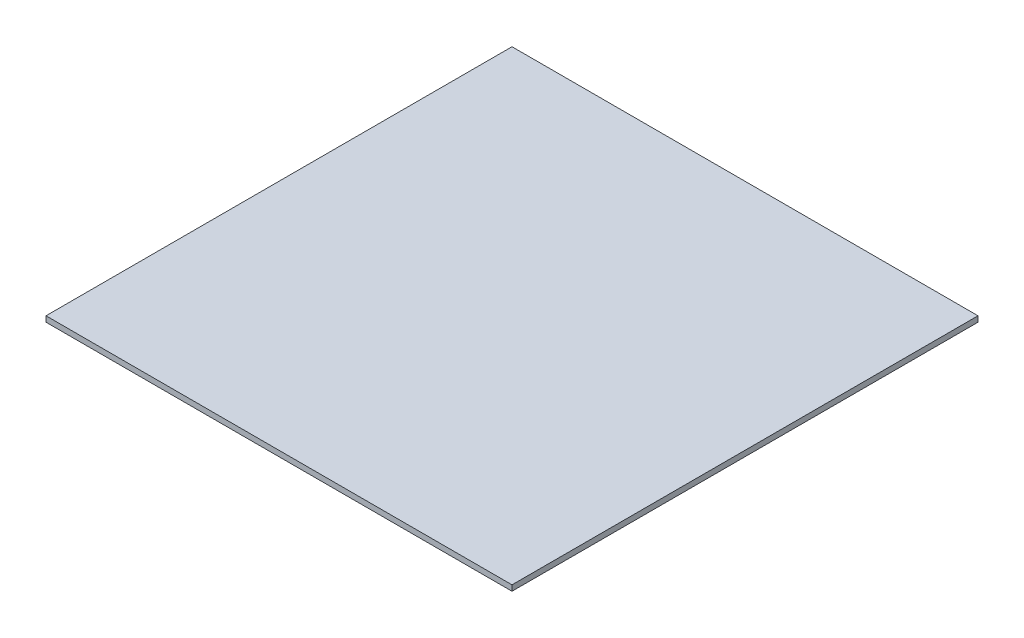
from build123d import *

# Parameters (mm, degrees)
SKETCH1_W           = 990.6
SKETCH1_H           = 990.6
BOSS_EXTRUDE1_DEPTH = 11.90625


with BuildPart() as part:
    # Sketch1 → Boss-Extrude1 (new body)
    with BuildSketch(Plane(origin=(0, 0, 0), x_dir=(1, 0, 0), z_dir=(0, 1, 0))):
        Rectangle(SKETCH1_W, SKETCH1_H)
    extrude(amount=BOSS_EXTRUDE1_DEPTH)


solid = part.part
